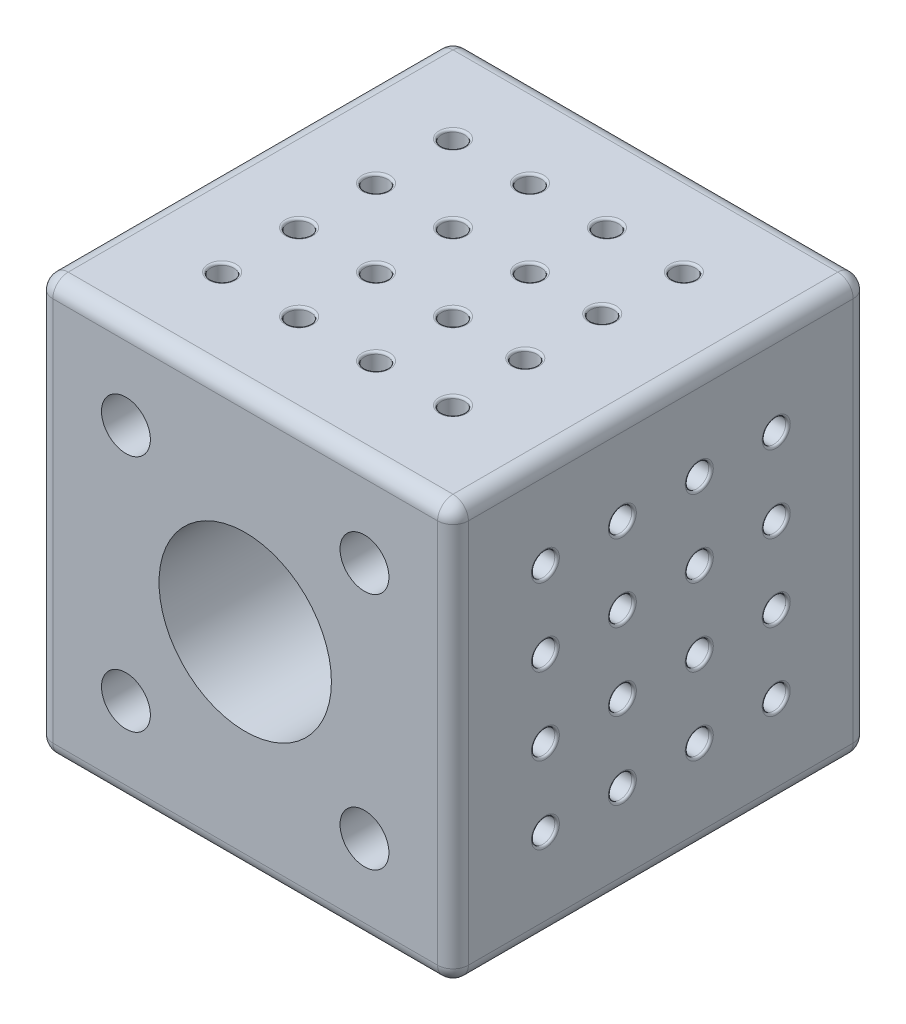
from build123d import *

# Parameters (mm, degrees)
SKETCH2_W                = 54
SKETCH2_H                = 54
BOSS_EXTRUDE1_DEPTH      = 54
BOSS_EXTRUDE1_DEPTH_BACK = 0.0001
FILLET1_R                = 2
FILLET2_R                = 2
SKETCH4_R                = 11.2
CUT_EXTRUDE1_DEPTH       = 17
SKETCH12_R               = 6.2
CUT_EXTRUDE2_DEPTH       = 33.5
SKETCH13_R               = 3.175
CUT_EXTRUDE3_DEPTH       = 21.5001
SKETCH15_R               = 1.5
CUT_EXTRUDE4_DEPTH       = 38.0001
SKETCH16_R               = 6.1
CUT_EXTRUDE5_DEPTH       = 38.0001
SKETCH17_R               = 11.2
CUT_EXTRUDE6_DEPTH       = 18
SKETCH18_R               = 11.1
CUT_EXTRUDE7_DEPTH       = 1
SKETCH19_R               = 1.5
CUT_EXTRUDE8_DEPTH       = 4
SKETCH21_R               = 1.525
CUT_EXTRUDE10_DEPTH      = 4
SKETCH22_R               = 1.5
SKETCH22_R_2             = 1.525
CUT_EXTRUDE11_DEPTH      = 4
SKETCH25_R               = 1.5
SKETCH25_R_2             = 1.525
CUT_EXTRUDE13_DEPTH      = 4
FILLET3_R                = 0.3
FILLET4_R                = 0.3
FILLET5_R                = 0.3
FILLET6_R                = 0.3


with BuildPart() as part:
    # Sketch2 → Boss-Extrude1 (new body, two sides)
    with BuildSketch(Plane.XY) as boss_extrude1_sk:
        with Locations((5.224836601, 7.517647059)):
            Rectangle(SKETCH2_W, SKETCH2_H)
    extrude(amount=BOSS_EXTRUDE1_DEPTH)
    extrude(boss_extrude1_sk.sketch, amount=-BOSS_EXTRUDE1_DEPTH_BACK)

    # Fillet1
    fillet1_edges = [part.edges().sort_by_distance(p)[0] for p in [
        (-21.775163399, 34.517647059, 26.99995),
        (32.224836601, 34.517647059, 26.99995),
        (32.224836601, -19.482352941, 26.99995),
        (-21.775163399, -19.482352941, 26.99995),
    ]]
    fillet(fillet1_edges, radius=FILLET1_R)

    # Fillet2
    fillet2_edges = [part.edges().sort_by_distance(p)[0] for p in [
        (-21.775163399, 7.517647059, 54),
        (-21.775163399, 7.517647059, -0.0001),
        (5.224836601, -19.482352941, 54),
        (32.224836601, 7.517647059, 54),
        (5.224836601, 34.517647059, 54),
        (31.639050164, 33.931860621, 54),
        (31.639050164, -18.896566504, 54),
        (-21.189376961, 33.931860621, 54),
        (-21.189376961, -18.896566504, 54),
        (5.224836601, -19.482352941, -0.0001),
        (5.224836601, 34.517647059, -0.0001),
        (32.224836601, 7.517647059, -0.0001),
        (31.639050164, 33.931860621, -0.0001),
        (31.639050164, -18.896566504, -0.0001),
        (-21.189376961, 33.931860621, -0.0001),
        (-21.189376961, -18.896566504, -0.0001),
    ]]
    fillet(fillet2_edges, radius=FILLET2_R)

    # Sketch4 → Cut-Extrude1 (cut)
    with BuildSketch(Plane(origin=(0, 0, -0.0001), x_dir=(-1, 0, 0), z_dir=(0, 0, -1))):
        with Locations((-5.224836601, 7.517647059)):
            Circle(SKETCH4_R)
    extrude(amount=-CUT_EXTRUDE1_DEPTH, mode=Mode.SUBTRACT)

    # Sketch12 → Cut-Extrude2 (cut)
    with BuildSketch(Plane(origin=(0, 0, -0.0001), x_dir=(-1, 0, 0), z_dir=(0, 0, -1))):
        with Locations((-20.724836601, 23.017647059)):
            Circle(SKETCH12_R)
        with Locations((10.275163399, 23.017647059)):
            Circle(SKETCH12_R)
        with Locations((-20.724836601, -7.982352941)):
            Circle(SKETCH12_R)
        with Locations((10.275163399, -7.982352941)):
            Circle(SKETCH12_R)
    extrude(amount=-CUT_EXTRUDE2_DEPTH, mode=Mode.SUBTRACT)

    # Sketch13 → Cut-Extrude3 (cut, through all)
    with BuildSketch(Plane(origin=(0, 0, 33.4999), x_dir=(-1, 0, 0), z_dir=(0, 0, -1))):
        with Locations((-20.724836601, 23.017647059)):
            Circle(SKETCH13_R)
        with Locations((10.275163399, 23.017647059)):
            Circle(SKETCH13_R)
        with Locations((10.275163399, -7.982352941)):
            Circle(SKETCH13_R)
        with Locations((-20.724836601, -7.982352941)):
            Circle(SKETCH13_R)
    extrude(amount=-CUT_EXTRUDE3_DEPTH, mode=Mode.SUBTRACT)

    # Sketch15 → Cut-Extrude4 (cut, through all)
    with BuildSketch(Plane(origin=(0, 0, 16.9999), x_dir=(-1, 0, 0), z_dir=(0, 0, -1))):
        with Locations((-5.224836601, 15.317647059)):
            Circle(SKETCH15_R)
        with Locations((-13.424836601, 7.517647059)):
            Circle(SKETCH15_R)
        with Locations((-5.224836601, -0.682352941)):
            Circle(SKETCH15_R)
        with Locations((2.575163399, 7.517647059)):
            Circle(SKETCH15_R)
    extrude(amount=-CUT_EXTRUDE4_DEPTH, mode=Mode.SUBTRACT)

    # Sketch16 → Cut-Extrude5 (cut, through all)
    with BuildSketch(Plane(origin=(0, 0, 16.9999), x_dir=(-1, 0, 0), z_dir=(0, 0, -1))):
        with Locations((-5.224836601, 7.517647059)):
            Circle(SKETCH16_R)
    extrude(amount=-CUT_EXTRUDE5_DEPTH, mode=Mode.SUBTRACT)

    # Sketch17 → Cut-Extrude6 (cut)
    with BuildSketch(Plane.XY.offset(54)):
        with Locations((5.224836601, 7.517647059)):
            Circle(SKETCH17_R)
    extrude(amount=-CUT_EXTRUDE6_DEPTH, mode=Mode.SUBTRACT)

    # Sketch18 → Cut-Extrude7 (cut)
    with BuildSketch(Plane(origin=(0, 0, 16.9999), x_dir=(-1, 0, 0), z_dir=(0, 0, -1))):
        with Locations((-5.224836601, 7.517647059)):
            Circle(SKETCH18_R)
    extrude(amount=-CUT_EXTRUDE7_DEPTH, mode=Mode.SUBTRACT)

    # Sketch19 → Cut-Extrude8 (cut)
    with BuildSketch(Plane(origin=(0, 34.517647059, 0), x_dir=(1, 0, 0), z_dir=(0, 1, 0))):
        with Locations((-9.775163399, -11.9999)):
            Circle(SKETCH19_R)
        with Locations((0.224836601, -11.9999)):
            Circle(SKETCH19_R)
        with Locations((10.224836601, -11.9999)):
            Circle(SKETCH19_R)
        with Locations((20.224836601, -11.9999)):
            Circle(SKETCH19_R)
        with Locations((-9.775163399, -21.9999)):
            Circle(SKETCH19_R)
        with Locations((0.224836601, -21.9999)):
            Circle(SKETCH19_R)
        with Locations((10.224836601, -21.9999)):
            Circle(SKETCH19_R)
        with Locations((19.610044829, -21.9999)):
            Circle(SKETCH19_R)
        with Locations((-9.775163399, -31.9999)):
            Circle(SKETCH19_R)
        with Locations((0.224836601, -31.9999)):
            Circle(SKETCH19_R)
        with Locations((10.224836601, -31.9999)):
            Circle(SKETCH19_R)
        with Locations((19.610044829, -31.9999)):
            Circle(SKETCH19_R)
        with Locations((-9.775163399, -41.9999)):
            Circle(SKETCH19_R)
        with Locations((0.224836601, -41.9999)):
            Circle(SKETCH19_R)
        with Locations((10.224836601, -42)):
            Circle(SKETCH19_R)
        with Locations((20.224836601, -42)):
            Circle(SKETCH19_R)
    extrude(amount=-CUT_EXTRUDE8_DEPTH, mode=Mode.SUBTRACT)

    # Sketch21 → Cut-Extrude10 (cut)
    with BuildSketch(Plane(origin=(32.224836601, 0, 0), x_dir=(0, -1, 0), z_dir=(1, 0, 0))):
        with Locations((-22.517647059, -12)):
            Circle(SKETCH21_R)
        with Locations((-12.517647059, -12)):
            Circle(SKETCH21_R)
        with Locations((-2.517647059, -12)):
            Circle(SKETCH21_R)
        with Locations((7.482352941, -12)):
            Circle(SKETCH21_R)
        with Locations((-22.517647059, -22)):
            Circle(SKETCH21_R)
        with Locations((-12.517647059, -22)):
            Circle(SKETCH21_R)
        with Locations((-2.517647059, -22)):
            Circle(SKETCH21_R)
        with Locations((7.482352941, -22)):
            Circle(SKETCH21_R)
        with Locations((-22.517647059, -32)):
            Circle(SKETCH21_R)
        with Locations((-12.517647059, -32)):
            Circle(SKETCH21_R)
        with Locations((-2.517647059, -32)):
            Circle(SKETCH21_R)
        with Locations((7.482352941, -32)):
            Circle(SKETCH21_R)
        with Locations((-22.517647059, -42)):
            Circle(SKETCH21_R)
        with Locations((-12.517647059, -42)):
            Circle(SKETCH21_R)
        with Locations((-2.517647059, -42)):
            Circle(SKETCH21_R)
        with Locations((7.482352941, -42)):
            Circle(SKETCH21_R)
    extrude(amount=-CUT_EXTRUDE10_DEPTH, mode=Mode.SUBTRACT)

    # Sketch22 → Cut-Extrude11 (cut)
    with BuildSketch(Plane(origin=(0, -19.482352941, 0), x_dir=(0, 0, 1), z_dir=(0, -1, 0))):
        with Locations((11.9999, 9.775163399)):
            Circle(SKETCH22_R)
        with Locations((21.9999, 9.775163399)):
            Circle(SKETCH22_R_2)
        with Locations((31.9999, 9.775163399)):
            Circle(SKETCH22_R)
        with Locations((41.9999, 9.775163399)):
            Circle(SKETCH22_R_2)
        with Locations((11.9999, -0.224836601)):
            Circle(SKETCH22_R_2)
        with Locations((21.9999, -0.224836601)):
            Circle(SKETCH22_R)
        with Locations((31.9999, -0.224836601)):
            Circle(SKETCH22_R_2)
        with Locations((41.9999, -0.224836601)):
            Circle(SKETCH22_R)
        with Locations((11.9999, -10.224836601)):
            Circle(SKETCH22_R)
        with Locations((21.9999, -10.224836601)):
            Circle(SKETCH22_R_2)
        with Locations((31.9999, -10.224836601)):
            Circle(SKETCH22_R)
        with Locations((41.9999, -10.224836601)):
            Circle(SKETCH22_R_2)
        with Locations((11.9999, -20.224836601)):
            Circle(SKETCH22_R_2)
        with Locations((21.9999, -20.224836601)):
            Circle(SKETCH22_R)
        with Locations((31.9999, -20.224836601)):
            Circle(SKETCH22_R_2)
        with Locations((41.9999, -20.224836601)):
            Circle(SKETCH22_R)
    extrude(amount=-CUT_EXTRUDE11_DEPTH, mode=Mode.SUBTRACT)

    # Sketch25 → Cut-Extrude13 (cut)
    with BuildSketch(Plane.ZY.offset(21.775163399)):
        with Locations((11.9999, 22.517647059)):
            Circle(SKETCH25_R)
        with Locations((21.9999, 22.517647059)):
            Circle(SKETCH25_R)
        with Locations((31.9999, 22.517647059)):
            Circle(SKETCH25_R)
        with Locations((41.9999, 22.517647059)):
            Circle(SKETCH25_R)
        with Locations((11.9999, 12.517647059)):
            Circle(SKETCH25_R_2)
        with Locations((21.9999, 12.517647059)):
            Circle(SKETCH25_R_2)
        with Locations((31.9999, 12.517647059)):
            Circle(SKETCH25_R_2)
        with Locations((41.9999, 12.517647059)):
            Circle(SKETCH25_R_2)
        with Locations((11.9999, 2.517647059)):
            Circle(SKETCH25_R_2)
        with Locations((21.9999, 2.517647059)):
            Circle(SKETCH25_R_2)
        with Locations((31.9999, 2.517647059)):
            Circle(SKETCH25_R_2)
        with Locations((41.9999, 2.517647059)):
            Circle(SKETCH25_R_2)
        with Locations((11.9999, -7.482352941)):
            Circle(SKETCH25_R)
        with Locations((21.9999, -7.482352941)):
            Circle(SKETCH25_R)
        with Locations((31.9999, -7.482352941)):
            Circle(SKETCH25_R)
        with Locations((41.9999, -7.482352941)):
            Circle(SKETCH25_R)
    extrude(amount=-CUT_EXTRUDE13_DEPTH, mode=Mode.SUBTRACT)

    # Fillet3
    fillet3_edges = [part.edges().sort_by_distance(p)[0] for p in [
        (-17.775163399, 12.517647059, 10.4749),
        (-21.775163399, 12.517647059, 10.4749),
        (-17.775163399, 12.517647059, 30.4749),
        (-21.775163399, 12.517647059, 30.4749),
        (-17.775163399, 12.517647059, 40.4749),
        (-21.775163399, 12.517647059, 40.4749),
        (-17.775163399, 2.517647059, 10.4749),
        (-21.775163399, 2.517647059, 10.4749),
        (-17.775163399, 22.517647059, 20.4999),
        (-21.775163399, 22.517647059, 20.4999),
        (-17.775163399, 22.517647059, 30.4999),
        (-21.775163399, 22.517647059, 30.4999),
        (-17.775163399, 22.517647059, 40.4999),
        (-21.775163399, 22.517647059, 40.4999),
        (-17.775163399, 12.517647059, 20.4749),
        (-21.775163399, 12.517647059, 20.4749),
        (-17.775163399, -7.482352941, 40.4999),
        (-21.775163399, -7.482352941, 40.4999),
        (-17.775163399, -7.482352941, 30.4999),
        (-21.775163399, -7.482352941, 30.4999),
        (-17.775163399, -7.482352941, 20.4999),
        (-21.775163399, -7.482352941, 20.4999),
        (-17.775163399, 2.517647059, 20.4749),
        (-21.775163399, 2.517647059, 20.4749),
        (-17.775163399, 2.517647059, 30.4749),
        (-21.775163399, 2.517647059, 30.4749),
        (-17.775163399, 2.517647059, 40.4749),
        (-21.775163399, 2.517647059, 40.4749),
        (-17.775163399, -7.482352941, 10.4999),
        (-21.775163399, -7.482352941, 10.4999),
        (-17.775163399, 22.517647059, 10.4999),
        (-21.775163399, 22.517647059, 10.4999),
    ]]
    fillet(fillet3_edges, radius=FILLET3_R)

    # Fillet4
    fillet4_edges = [part.edges().sort_by_distance(p)[0] for p in [
        (0.224836601, -15.482352941, 10.4749),
        (0.224836601, -19.482352941, 10.4749),
        (0.224836601, -15.482352941, 30.4749),
        (0.224836601, -19.482352941, 30.4749),
        (0.224836601, -15.482352941, 40.4999),
        (0.224836601, -19.482352941, 40.4999),
        (10.224836601, -15.482352941, 10.4999),
        (10.224836601, -19.482352941, 10.4999),
        (-9.775163399, -15.482352941, 20.4749),
        (-9.775163399, -19.482352941, 20.4749),
        (-9.775163399, -15.482352941, 30.4999),
        (-9.775163399, -19.482352941, 30.4999),
        (-9.775163399, -15.482352941, 40.4749),
        (-9.775163399, -19.482352941, 40.4749),
        (0.224836601, -15.482352941, 20.4999),
        (0.224836601, -19.482352941, 20.4999),
        (20.224836601, -15.482352941, 40.4999),
        (20.224836601, -19.482352941, 40.4999),
        (20.224836601, -15.482352941, 30.4749),
        (20.224836601, -19.482352941, 30.4749),
        (20.224836601, -15.482352941, 20.4999),
        (20.224836601, -19.482352941, 20.4999),
        (10.224836601, -15.482352941, 20.4749),
        (10.224836601, -19.482352941, 20.4749),
        (10.224836601, -15.482352941, 30.4999),
        (10.224836601, -19.482352941, 30.4999),
        (10.224836601, -15.482352941, 40.4749),
        (10.224836601, -19.482352941, 40.4749),
        (20.224836601, -15.482352941, 10.4749),
        (20.224836601, -19.482352941, 10.4749),
        (-9.775163399, -15.482352941, 10.4999),
        (-9.775163399, -19.482352941, 10.4999),
    ]]
    fillet(fillet4_edges, radius=FILLET4_R)

    # Fillet5
    fillet5_edges = [part.edges().sort_by_distance(p)[0] for p in [
        (28.224836601, 24.042647059, 22),
        (32.224836601, 24.042647059, 22),
        (28.224836601, 4.042647059, 22),
        (32.224836601, 4.042647059, 22),
        (28.224836601, -5.957352941, 22),
        (32.224836601, -5.957352941, 22),
        (28.224836601, 24.042647059, 32),
        (32.224836601, 24.042647059, 32),
        (28.224836601, 14.042647059, 12),
        (32.224836601, 14.042647059, 12),
        (28.224836601, 4.042647059, 12),
        (32.224836601, 4.042647059, 12),
        (28.224836601, -5.957352941, 12),
        (32.224836601, -5.957352941, 12),
        (28.224836601, 14.042647059, 22),
        (32.224836601, 14.042647059, 22),
        (28.224836601, -5.957352941, 42),
        (32.224836601, -5.957352941, 42),
        (28.224836601, 4.042647059, 42),
        (32.224836601, 4.042647059, 42),
        (28.224836601, 14.042647059, 42),
        (32.224836601, 14.042647059, 42),
        (28.224836601, 14.042647059, 32),
        (32.224836601, 14.042647059, 32),
        (28.224836601, 4.042647059, 32),
        (32.224836601, 4.042647059, 32),
        (28.224836601, -5.957352941, 32),
        (32.224836601, -5.957352941, 32),
        (28.224836601, 24.042647059, 42),
        (32.224836601, 24.042647059, 42),
        (28.224836601, 24.042647059, 12),
        (32.224836601, 24.042647059, 12),
    ]]
    fillet(fillet5_edges, radius=FILLET5_R)

    # Fillet6
    fillet6_edges = [part.edges().sort_by_distance(p)[0] for p in [
        (-11.275163399, 30.517647059, 21.9999),
        (-11.275163399, 34.517647059, 21.9999),
        (8.724836601, 30.517647059, 21.9999),
        (8.724836601, 34.517647059, 21.9999),
        (18.110044829, 30.517647059, 21.9999),
        (18.110044829, 34.517647059, 21.9999),
        (-11.275163399, 30.517647059, 31.9999),
        (-11.275163399, 34.517647059, 31.9999),
        (-1.275163399, 30.517647059, 11.9999),
        (-1.275163399, 34.517647059, 11.9999),
        (8.724836601, 30.517647059, 11.9999),
        (8.724836601, 34.517647059, 11.9999),
        (18.724836601, 30.517647059, 11.9999),
        (18.724836601, 34.517647059, 11.9999),
        (-1.275163399, 30.517647059, 21.9999),
        (-1.275163399, 34.517647059, 21.9999),
        (18.724836601, 30.517647059, 42),
        (18.724836601, 34.517647059, 42),
        (8.724836601, 30.517647059, 42),
        (8.724836601, 34.517647059, 42),
        (-1.275163399, 30.517647059, 41.9999),
        (-1.275163399, 34.517647059, 41.9999),
        (-1.275163399, 30.517647059, 31.9999),
        (-1.275163399, 34.517647059, 31.9999),
        (8.724836601, 30.517647059, 31.9999),
        (8.724836601, 34.517647059, 31.9999),
        (18.110044829, 30.517647059, 31.9999),
        (18.110044829, 34.517647059, 31.9999),
        (-11.275163399, 30.517647059, 41.9999),
        (-11.275163399, 34.517647059, 41.9999),
        (-11.275163399, 30.517647059, 11.9999),
        (-11.275163399, 34.517647059, 11.9999),
    ]]
    fillet(fillet6_edges, radius=FILLET6_R)


solid = part.part
